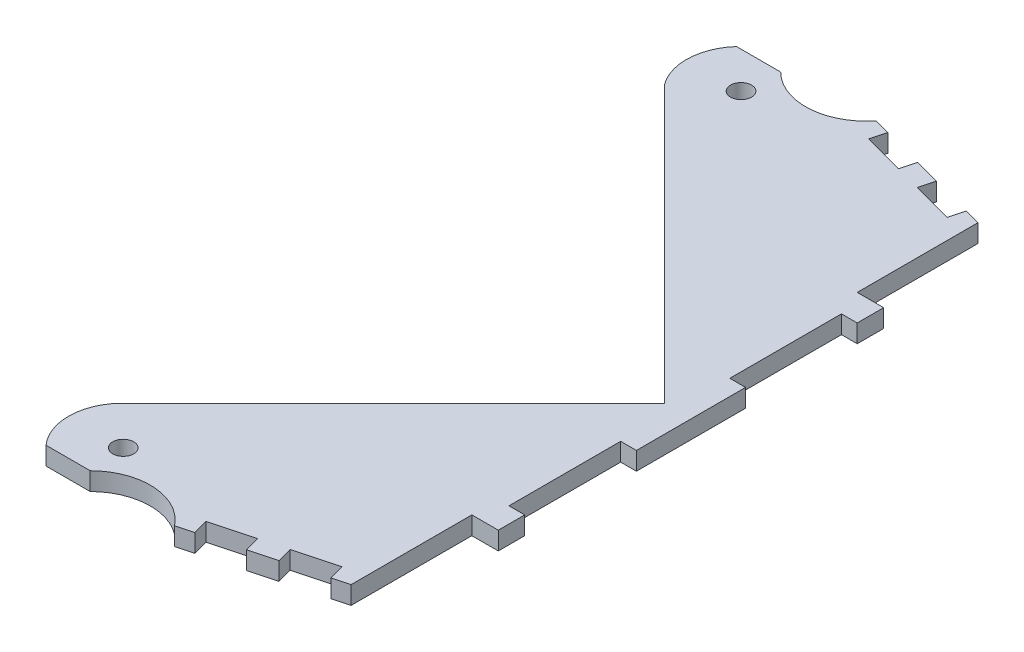
from build123d import *

# Parameters (mm, degrees)
SKETCH1_R           = 3.175
BOSS_EXTRUDE1_DEPTH = 5.461
SKETCH2_W           = 4.7625
SKETCH2_H           = 33.783
CUT_EXTRUDE1_DEPTH  = 138.241751927


with BuildPart() as part:
    # Sketch1 → Boss-Extrude1 (new body)
    with BuildSketch(Plane(origin=(0, 0, 0), x_dir=(1, 0, 0), z_dir=(0, 1, 0))):
        with BuildLine():
            Line((-82.674132744, 104.451069294), (-69.310188895, 104.451069294))
            ThreePointArc((-69.310188895, 104.451069294), (-55.336180049, 99.157726681), (-42.113057451, 106.117714323))
            Line((-42.113057451, 106.117714323), (0, 94.833554589))
            Line((0, 94.833554589), (0, 58.293))
            Line((0, 58.293), (8, 58.293))
            Line((8, 58.293), (8, -58.293))
            Line((8, -58.293), (0, -58.293))
            Line((0, -58.293), (0, -94.833554589))
            Line((0, -94.833554589), (-42.113057451, -106.117714323))
            ThreePointArc((-42.113057451, -106.117714323), (-55.336180049, -99.157726681), (-69.310188895, -104.451069294))
            Line((-69.310188895, -104.451069294), (-82.674132744, -104.451069294))
            ThreePointArc((-82.674132744, -104.451069294), (-86.841727728, -94.209575285), (-83.629476528, -83.629476528))
            Line((-83.629476528, -83.629476528), (0, 0))
            Line((0, 0), (-83.629476528, 83.629476528))
            ThreePointArc((-83.629476528, 83.629476528), (-86.841727728, 94.209575285), (-82.674132744, 104.451069294))
        make_face()
        with Locations((-70.310188895, 93.451069294)):
            Circle(SKETCH1_R, mode=Mode.SUBTRACT)
        with Locations((-70.310188895, -93.451069294)):
            Circle(SKETCH1_R, mode=Mode.SUBTRACT)
    extrude(amount=BOSS_EXTRUDE1_DEPTH)

    # Sketch2 → Cut-Extrude1 (cut, through all)
    with BuildSketch(Plane(origin=(0, 0, 0), x_dir=(1, 0, 0), z_dir=(0, 1, 0))):
        Polygon((-17.19282542, -99.440358276), (-4.829629131, -96.127649814), (-6.062254834, -91.527428067), (-18.425451123, -94.840136528), align=None)
        Polygon((-37.283428319, -104.823619098), (-24.920232031, -101.510910637), (-26.152857733, -96.910688889), (-38.516054022, -100.22339735), align=None)
        with Locations((5.61875, -33.4015)):
            Rectangle(SKETCH2_W, SKETCH2_H)
        Polygon((-38.516054022, 100.22339735), (-26.152857733, 96.910688889), (-24.920232031, 101.510910637), (-37.283428319, 104.823619098), align=None)
        Polygon((-18.425451123, 94.840136528), (-6.062254834, 91.527428067), (-4.829629131, 96.127649814), (-17.19282542, 99.440358276), align=None)
        with Locations((5.61875, 33.4015)):
            Rectangle(SKETCH2_W, SKETCH2_H)
    extrude(amount=CUT_EXTRUDE1_DEPTH, mode=Mode.SUBTRACT)


solid = part.part
